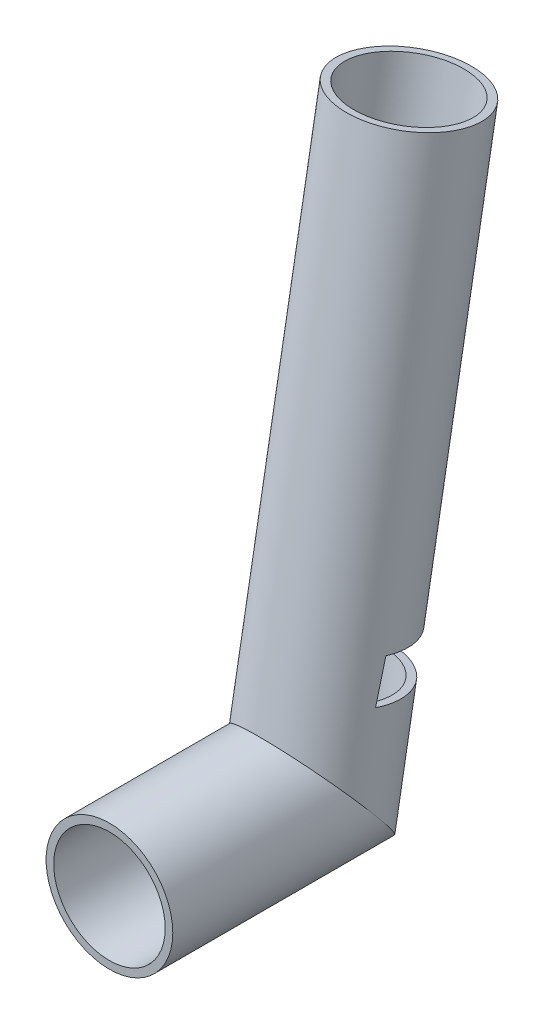
from build123d import *

# Parameters (mm, degrees)
SKETCH3_R               = 25
SKETCH3_R_2             = 22
CUT_EXTRUDE2_DEPTH      = 26
CUT_EXTRUDE2_DEPTH_BACK = 26


with BuildPart() as part:
    # Sweep1: sweep along a path in Sketch1
    with BuildLine(Plane(origin=(0, 0, 0), x_dir=(0, 0, -1), z_dir=(1, 0, 0))) as sweep1_path:
        Line((0, 0), (80, 0))
        Line((80, 0), (118.202599087, 216.657705663))
    # Sketch3 → Sweep1 (sweep)
    with BuildSketch(Plane.XY):
        Circle(SKETCH3_R)
        Circle(SKETCH3_R_2, mode=Mode.SUBTRACT)
    sweep(path=sweep1_path.line, transition=Transition.RIGHT)

    # Sketch4 → Cut-Extrude2 (cut, two sides)
    with BuildSketch(Plane(origin=(0, 0, 0), x_dir=(0, 0, -1), z_dir=(1, 0, 0))) as cut_extrude2_sk:
        Polygon((110.842308967, 30.946164041), (113.687194162, 47.080309724), (94.794337041, 50.411630176), (84.524899127, 52.222409157), (80.652201417, 36.269494553), align=None)
    extrude(amount=CUT_EXTRUDE2_DEPTH, mode=Mode.SUBTRACT)
    extrude(cut_extrude2_sk.sketch, amount=-CUT_EXTRUDE2_DEPTH_BACK, mode=Mode.SUBTRACT)


solid = part.part
